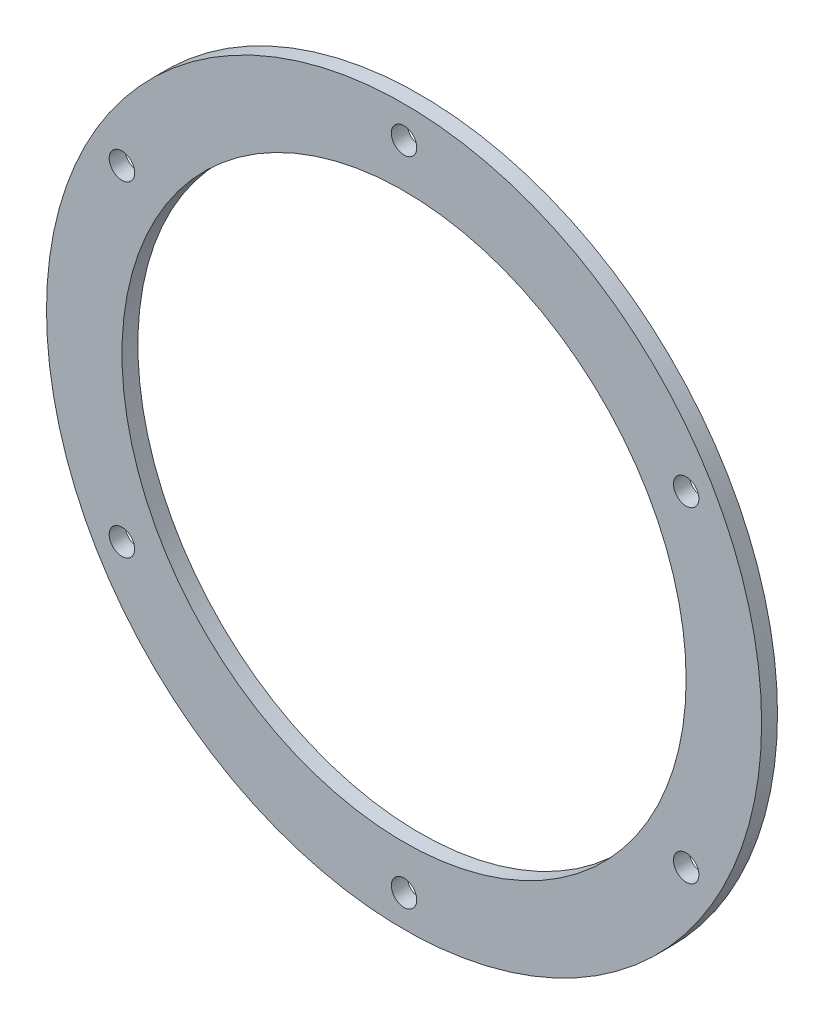
from build123d import *

# Parameters (mm, degrees)
SKETCH_1_R      = 45
SKETCH_1_R_2    = 35.5
SKETCH_1_R_3    = 1.6
EXTRUDE_1_DEPTH = 2


with BuildPart() as part:
    # 草图1 → 凸台-拉伸1 (new body)
    with BuildSketch(Plane.XY):
        Circle(SKETCH_1_R)
        Circle(SKETCH_1_R_2, mode=Mode.SUBTRACT)
        with Locations((0, 41)):
            Circle(SKETCH_1_R_3, mode=Mode.SUBTRACT)
        with Locations((35.507041555, 20.5)):
            Circle(SKETCH_1_R_3, mode=Mode.SUBTRACT)
        with Locations((35.507041555, -20.5)):
            Circle(SKETCH_1_R_3, mode=Mode.SUBTRACT)
        with Locations((0, -41)):
            Circle(SKETCH_1_R_3, mode=Mode.SUBTRACT)
        with Locations((-35.507041555, -20.5)):
            Circle(SKETCH_1_R_3, mode=Mode.SUBTRACT)
        with Locations((-35.507041555, 20.5)):
            Circle(SKETCH_1_R_3, mode=Mode.SUBTRACT)
    extrude(amount=EXTRUDE_1_DEPTH)


solid = part.part
